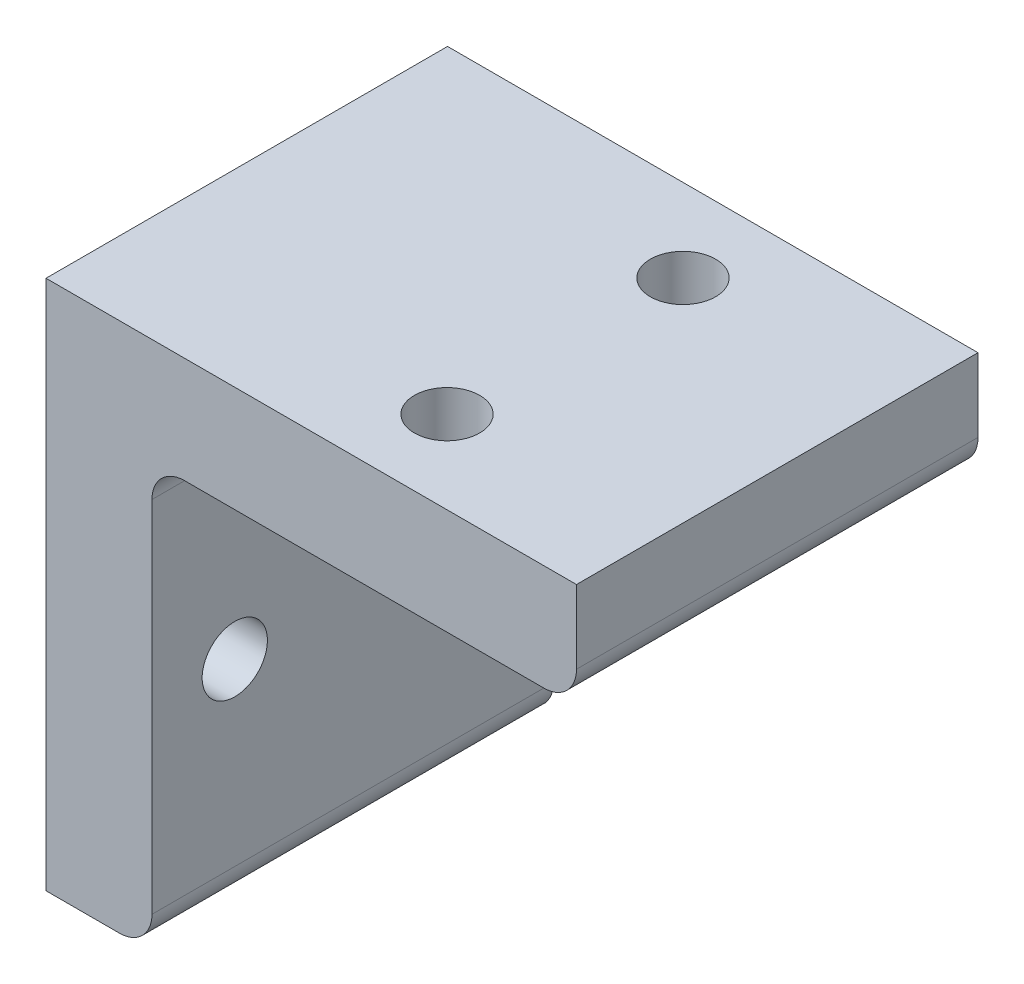
from build123d import *

# Parameters (mm, degrees)
SKETCH1_W           = 34.0614
SKETCH1_H           = 45
BOSS_EXTRUDE1_DEPTH = 8.9916
SKETCH2_W           = 34.0614
SKETCH2_H           = 8.9916
BOSS_EXTRUDE2_DEPTH = 36.0084
CUT_EXTRUDE2_REACH  = 10.992
SKETCH5_R           = 2.7686
SKETCH5_R_2         = 2.6416
CUT_EXTRUDE3_REACH  = 47
SKETCH6_R           = 2.7686
FILLET1_R           = 2.7686


with BuildPart() as part:
    # Sketch1 → Boss-Extrude1 (new body)
    with BuildSketch(Plane(origin=(0, 0, 0), x_dir=(0, 0, -1), z_dir=(1, 0, 0))):
        Rectangle(SKETCH1_W, SKETCH1_H)
    extrude(amount=BOSS_EXTRUDE1_DEPTH)

    # Sketch2 → Boss-Extrude2 (add)
    with BuildSketch(Plane(origin=(8.9916, 0, 0), x_dir=(0, 0, -1), z_dir=(1, 0, 0))):
        with Locations((0, 18.0042)):
            Rectangle(SKETCH2_W, SKETCH2_H)
    extrude(amount=BOSS_EXTRUDE2_DEPTH)

    # Sketch5 → Cut-Extrude2 (cut, up to next)
    with BuildSketch(Plane(origin=(8.9916, 0, 0), x_dir=(0, 0, -1), z_dir=(1, 0, 0)), mode=Mode.PRIVATE) as cut_extrude2_sk1:
        with Locations((-10.0076, -4.4958)):
            Circle(SKETCH5_R)
    cut_extrude2_tool1 = extrude(cut_extrude2_sk1.sketch, amount=-CUT_EXTRUDE2_REACH, mode=Mode.PRIVATE) & part.part
    add(cut_extrude2_tool1.solids().sort_by_distance((8.9916, -4.4958, 10.0076))[0], mode=Mode.SUBTRACT)
    # Sketch5 → Cut-Extrude2 (cut, up to next)
    with BuildSketch(Plane(origin=(8.9916, 0, 0), x_dir=(0, 0, -1), z_dir=(1, 0, 0)), mode=Mode.PRIVATE) as cut_extrude2_sk2:
        with Locations((10.0076, -4.4958)):
            Circle(SKETCH5_R_2)
    cut_extrude2_tool2 = extrude(cut_extrude2_sk2.sketch, amount=-CUT_EXTRUDE2_REACH, mode=Mode.PRIVATE) & part.part
    add(cut_extrude2_tool2.solids().sort_by_distance((8.9916, -4.4958, -10.0076))[0], mode=Mode.SUBTRACT)

    # Sketch6 → Cut-Extrude3 (cut, up to next)
    with BuildSketch(Plane(origin=(0, 22.5, 0), x_dir=(1, 0, 0), z_dir=(0, 1, 0)), mode=Mode.PRIVATE) as cut_extrude3_sk1:
        with Locations((26.995718, 10.0076)):
            Circle(SKETCH6_R)
    cut_extrude3_tool1 = extrude(cut_extrude3_sk1.sketch, amount=-CUT_EXTRUDE3_REACH, mode=Mode.PRIVATE) & part.part
    add(cut_extrude3_tool1.solids().sort_by_distance((26.995718, 22.5, -10.0076))[0], mode=Mode.SUBTRACT)
    # Sketch6 → Cut-Extrude3 (cut, up to next)
    with BuildSketch(Plane(origin=(0, 22.5, 0), x_dir=(1, 0, 0), z_dir=(0, 1, 0)), mode=Mode.PRIVATE) as cut_extrude3_sk2:
        with Locations((26.995718, -10.0076)):
            Circle(SKETCH6_R)
    cut_extrude3_tool2 = extrude(cut_extrude3_sk2.sketch, amount=-CUT_EXTRUDE3_REACH, mode=Mode.PRIVATE) & part.part
    add(cut_extrude3_tool2.solids().sort_by_distance((26.995718, 22.5, 10.0076))[0], mode=Mode.SUBTRACT)

    # Fillet1
    fillet1_edges = [part.edges().sort_by_distance(p)[0] for p in [
        (8.9916, -22.5, 0),
        (8.9916, 13.5084, 0),
        (45, 13.5084, 0),
    ]]
    fillet(fillet1_edges, radius=FILLET1_R)


solid = part.part
